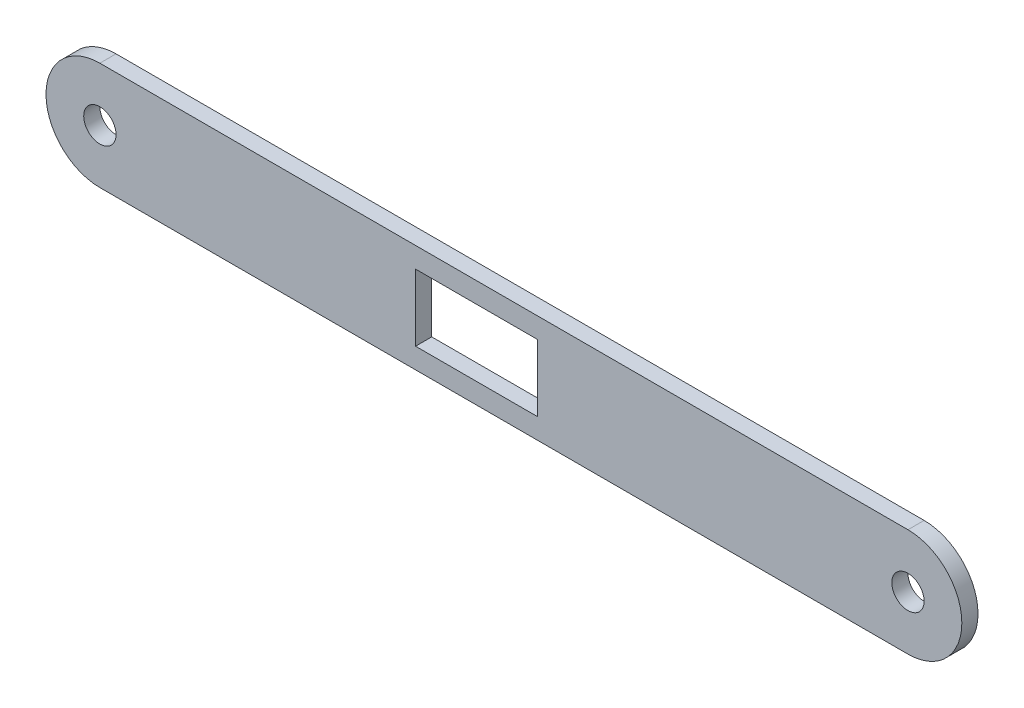
from build123d import *

# Parameters (mm, degrees)
SKETCH1_R           = 3
SKETCH1_W           = 22.6
SKETCH1_H           = 12.4
BOSS_EXTRUDE1_DEPTH = 3


with BuildPart() as part:
    # Sketch1 → Boss-Extrude1 (new body)
    with BuildSketch(Plane.XY):
        with BuildLine():
            Line((75, -10), (-75, -10))
            ThreePointArc((-75, -10), (-85, 0), (-75, 10))
            Line((-75, 10), (75, 10))
            ThreePointArc((75, 10), (85, 0), (75, -10))
        make_face()
        with Locations((75, 0)):
            Circle(SKETCH1_R, mode=Mode.SUBTRACT)
        with Locations((-75, 0)):
            Circle(SKETCH1_R, mode=Mode.SUBTRACT)
        with Locations((-5.1, 0)):
            Rectangle(SKETCH1_W, SKETCH1_H, mode=Mode.SUBTRACT)
    extrude(amount=BOSS_EXTRUDE1_DEPTH)


solid = part.part
